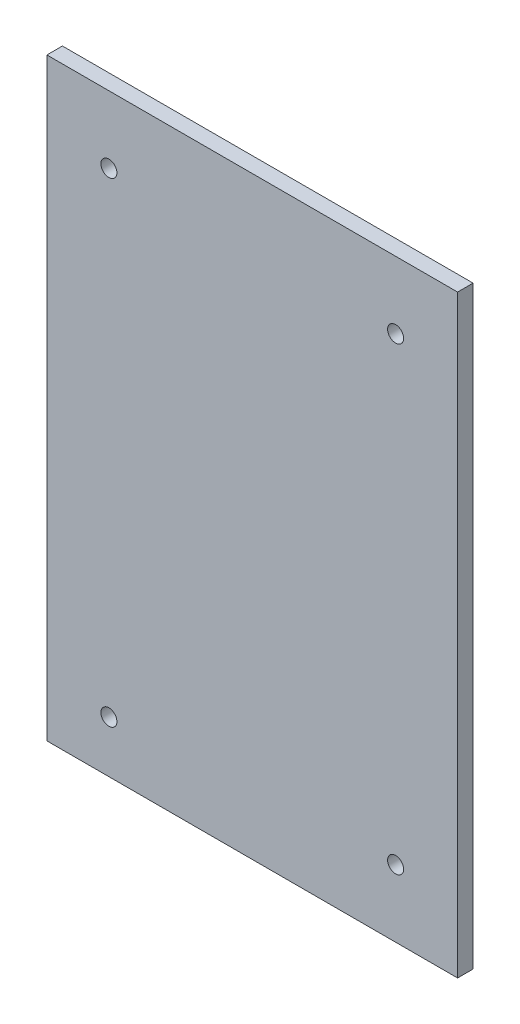
from build123d import *

# Parameters (mm, degrees)
SKETCH1_W           = 79.5
SKETCH1_H           = 115
SKETCH1_R           = 1.55
BOSS_EXTRUDE1_DEPTH = 3


with BuildPart() as part:
    # Sketch1 → Boss-Extrude1 (new body)
    with BuildSketch(Plane.XY):
        Rectangle(SKETCH1_W, SKETCH1_H)
        with Locations((-27.75, 44.5)):
            Circle(SKETCH1_R, mode=Mode.SUBTRACT)
        with Locations((27.75, 44.5)):
            Circle(SKETCH1_R, mode=Mode.SUBTRACT)
        with Locations((27.75, -44.5)):
            Circle(SKETCH1_R, mode=Mode.SUBTRACT)
        with Locations((-27.75, -47.5)):
            Circle(SKETCH1_R, mode=Mode.SUBTRACT)
    extrude(amount=BOSS_EXTRUDE1_DEPTH)


solid = part.part
